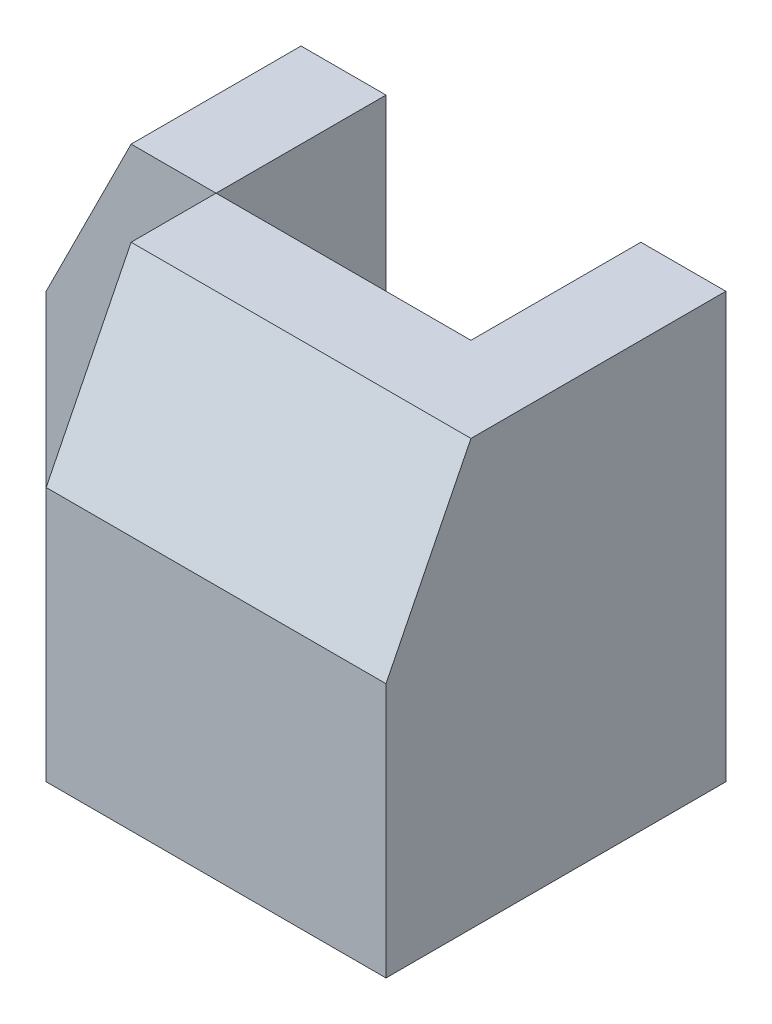
from build123d import *

# Parameters (mm, degrees)
SKETCH1_W           = 30
SKETCH1_H           = 25
BOSS_EXTRUDE1_DEPTH = 20
SKETCH2_W           = 10
SKETCH2_H           = 25
CUT_EXTRUDE1_DEPTH  = 10
CUT_EXTRUDE2_DEPTH  = 10
SKETCH4_W           = 10
SKETCH4_H           = 25
CUT_EXTRUDE4_DEPTH  = 10
CUT_EXTRUDE5_DEPTH  = 10
CUT_EXTRUDE6_DEPTH  = 20


with BuildPart() as part:
    # Sketch1 → Boss-Extrude1 (new body)
    with BuildSketch(Plane.XY):
        with Locations((15, 12.5)):
            Rectangle(SKETCH1_W, SKETCH1_H)
    extrude(amount=BOSS_EXTRUDE1_DEPTH)

    # Sketch2 → Cut-Extrude1 (cut)
    with BuildSketch(Plane.XY.offset(20)):
        with Locations((5, 12.5)):
            Rectangle(SKETCH2_W, SKETCH2_H)
    extrude(amount=-CUT_EXTRUDE1_DEPTH, mode=Mode.SUBTRACT)

    # Sketch3 → Cut-Extrude2 (cut)
    with BuildSketch(Plane.XY.offset(10)):
        Polygon((0, 25), (5, 25), (0, 15), align=None)
    extrude(amount=-CUT_EXTRUDE2_DEPTH, mode=Mode.SUBTRACT)

    # Sketch4 → Cut-Extrude4 (cut)
    with BuildSketch(Plane(origin=(0, 0, 0), x_dir=(-1, 0, 0), z_dir=(0, 0, -1))):
        with Locations((-15, 12.5)):
            Rectangle(SKETCH4_W, SKETCH4_H)
    extrude(amount=-CUT_EXTRUDE4_DEPTH, mode=Mode.SUBTRACT)

    # Sketch5 → Cut-Extrude5 (cut)
    with BuildSketch(Plane(origin=(0, 0, 0), x_dir=(-1, 0, 0), z_dir=(0, 0, -1))):
        Polygon((-25, 25), (-20, 15), (-20, 25), align=None)
    extrude(amount=-CUT_EXTRUDE5_DEPTH, mode=Mode.SUBTRACT)

    # Sketch6 → Cut-Extrude6 (cut)
    with BuildSketch(Plane.ZY.offset(-10)):
        Polygon((15, 25), (20, 15), (20, 25), align=None)
    extrude(amount=-CUT_EXTRUDE6_DEPTH, mode=Mode.SUBTRACT)


solid = part.part
